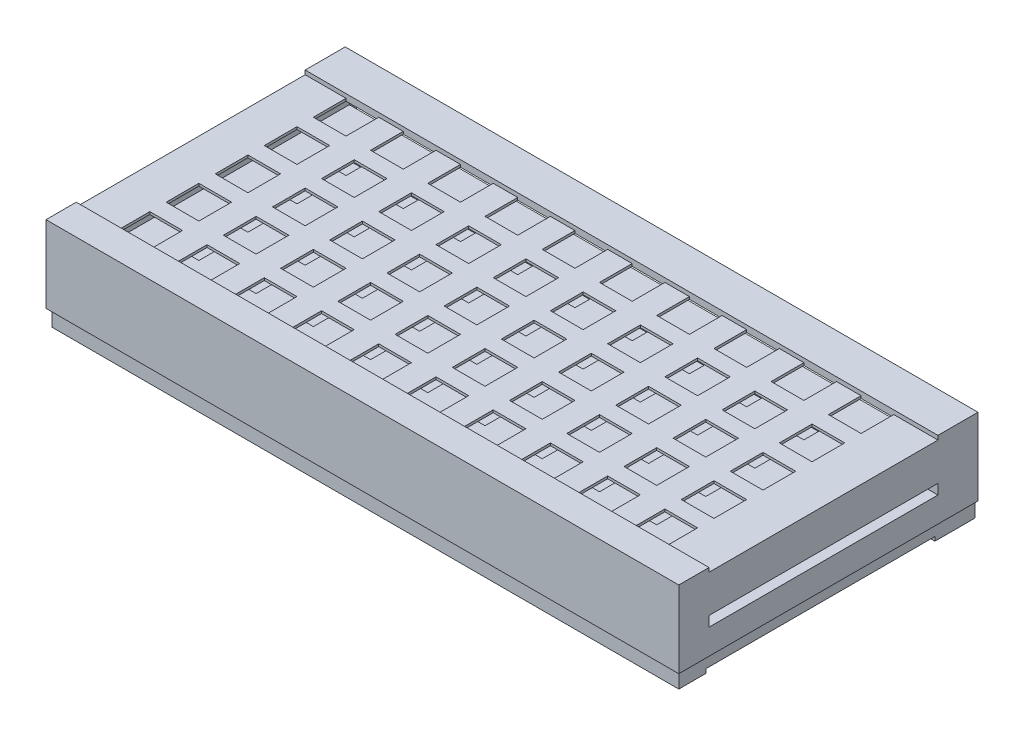
from build123d import *

# Parameters (mm, degrees)
SZKIC1_W                     = 374
SZKIC1_H                     = 53
DODANIE_WYCI_GNI_CIE1_DEPTH  = 177
SZKIC5_W                     = 20
SZKIC5_H                     = 20
WYTNIJ_WYCI_GNI_CIE4_DEPTH   = 104
SZKIC7_W                     = 370
SZKIC7_H                     = 19.4
WYTNIJ_WYCI_GNI_CIE5_DEPTH   = 175
SZKIC9_W                     = 140
SZKIC9_H                     = 6.2
WYTNIJ_WYCI_GNI_CIE6_DEPTH   = 374
SZKIC15_W                    = 374
SZKIC15_H                    = 177
SZKIC15_W_2                  = 20
SZKIC15_H_2                  = 20
DODANIE_WYCI_GNI_CIE6_DEPTH  = 1
SZKIC16_W                    = 374
SZKIC16_H                    = 177
SZKIC16_W_2                  = 20
SZKIC16_H_2                  = 20
DODANIE_WYCI_GNI_CIE7_DEPTH  = 1
SZKIC17_W                    = 177
SZKIC17_H                    = 55
SZKIC17_W_2                  = 140
SZKIC17_H_2                  = 6.2
DODANIE_WYCI_GNI_CIE8_DEPTH  = 1
SZKIC18_W                    = 177
SZKIC18_H                    = 55
SZKIC18_W_2                  = 140
SZKIC18_H_2                  = 6.2
DODANIE_WYCI_GNI_CIE9_DEPTH  = 1
SZKIC19_W                    = 376
SZKIC19_H                    = 55
SZKIC19_W_2                  = 373
SZKIC19_H_2                  = 52
DODANIE_WYCI_GNI_CIE10_DEPTH = 6
SZKIC21_W                    = 376
SZKIC21_H                    = 140
WYTNIJ_WYCI_GNI_CIE7_DEPTH   = 1.5
SZKIC22_W                    = 376
SZKIC22_H                    = 140
WYTNIJ_WYCI_GNI_CIE8_DEPTH   = 1.5
SZKIC23_W                    = 140
SZKIC23_H                    = 6.2
DODANIE_WYCI_GNI_CIE11_DEPTH = 5.5
SZKIC24_W                    = 140
SZKIC24_H                    = 6.2
DODANIE_WYCI_GNI_CIE12_DEPTH = 5.5
SZKIC25_W                    = 387
SZKIC25_H                    = 24.5
SZKIC25_H_2                  = 18.5
DODANIE_WYCI_GNI_CIE13_DEPTH = 1
SZKIC26_W                    = 387
SZKIC26_H                    = 24.5
SZKIC26_H_2                  = 18.5
DODANIE_WYCI_GNI_CIE14_DEPTH = 1
SZKIC31_W                    = 387
SZKIC31_H                    = 10
WYTNIJ_WYCI_GNI_CIE12_DEPTH  = 1.85
WYTNIJ_WYCI_GNI_CIE13_DEPTH  = 1.85
WYTNIJ_WYCI_GNI_CIE14_DEPTH  = 1.85


with BuildPart() as part:
    # Szkic1 → Dodanie-wyciągnięcie1 (new body)
    with BuildSketch(Plane.XY):
        with Locations((-1, 7.6)):
            Rectangle(SZKIC1_W, SZKIC1_H)
    extrude(amount=DODANIE_WYCI_GNI_CIE1_DEPTH)

    # Szkic5 → Wytnij-wyciągnięcie4 (cut)
    with BuildSketch(Plane.XZ.offset(18.9)):
        with Locations((155.5, 58.5)):
            Rectangle(SZKIC5_W, SZKIC5_H)
        with Locations((155.5, 28.5)):
            Rectangle(SZKIC5_W, SZKIC5_H)
        with Locations((155.5, 88.5)):
            Rectangle(SZKIC5_W, SZKIC5_H)
        with Locations((155.5, 118.5)):
            Rectangle(SZKIC5_W, SZKIC5_H)
        with Locations((155.5, 148.5)):
            Rectangle(SZKIC5_W, SZKIC5_H)
        with Locations((120.5, 58.5)):
            Rectangle(SZKIC5_W, SZKIC5_H)
        with Locations((120.5, 28.5)):
            Rectangle(SZKIC5_W, SZKIC5_H)
        with Locations((120.5, 88.5)):
            Rectangle(SZKIC5_W, SZKIC5_H)
        with Locations((120.5, 118.5)):
            Rectangle(SZKIC5_W, SZKIC5_H)
        with Locations((120.5, 148.5)):
            Rectangle(SZKIC5_W, SZKIC5_H)
        with Locations((85.5, 58.5)):
            Rectangle(SZKIC5_W, SZKIC5_H)
        with Locations((85.5, 28.5)):
            Rectangle(SZKIC5_W, SZKIC5_H)
        with Locations((85.5, 88.5)):
            Rectangle(SZKIC5_W, SZKIC5_H)
        with Locations((85.5, 118.5)):
            Rectangle(SZKIC5_W, SZKIC5_H)
        with Locations((85.5, 148.5)):
            Rectangle(SZKIC5_W, SZKIC5_H)
        with Locations((50.5, 58.5)):
            Rectangle(SZKIC5_W, SZKIC5_H)
        with Locations((50.5, 28.5)):
            Rectangle(SZKIC5_W, SZKIC5_H)
        with Locations((50.5, 88.5)):
            Rectangle(SZKIC5_W, SZKIC5_H)
        with Locations((50.5, 118.5)):
            Rectangle(SZKIC5_W, SZKIC5_H)
        with Locations((50.5, 148.5)):
            Rectangle(SZKIC5_W, SZKIC5_H)
        with Locations((15.5, 58.5)):
            Rectangle(SZKIC5_W, SZKIC5_H)
        with Locations((15.5, 28.5)):
            Rectangle(SZKIC5_W, SZKIC5_H)
        with Locations((15.5, 88.5)):
            Rectangle(SZKIC5_W, SZKIC5_H)
        with Locations((15.5, 118.5)):
            Rectangle(SZKIC5_W, SZKIC5_H)
        with Locations((15.5, 148.5)):
            Rectangle(SZKIC5_W, SZKIC5_H)
        with Locations((-19.5, 58.5)):
            Rectangle(SZKIC5_W, SZKIC5_H)
        with Locations((-19.5, 28.5)):
            Rectangle(SZKIC5_W, SZKIC5_H)
        with Locations((-19.5, 88.5)):
            Rectangle(SZKIC5_W, SZKIC5_H)
        with Locations((-19.5, 118.5)):
            Rectangle(SZKIC5_W, SZKIC5_H)
        with Locations((-19.5, 148.5)):
            Rectangle(SZKIC5_W, SZKIC5_H)
        with Locations((-54.5, 58.5)):
            Rectangle(SZKIC5_W, SZKIC5_H)
        with Locations((-54.5, 28.5)):
            Rectangle(SZKIC5_W, SZKIC5_H)
        with Locations((-54.5, 88.5)):
            Rectangle(SZKIC5_W, SZKIC5_H)
        with Locations((-54.5, 118.5)):
            Rectangle(SZKIC5_W, SZKIC5_H)
        with Locations((-54.5, 148.5)):
            Rectangle(SZKIC5_W, SZKIC5_H)
        with Locations((-89.5, 58.5)):
            Rectangle(SZKIC5_W, SZKIC5_H)
        with Locations((-89.5, 28.5)):
            Rectangle(SZKIC5_W, SZKIC5_H)
        with Locations((-89.5, 88.5)):
            Rectangle(SZKIC5_W, SZKIC5_H)
        with Locations((-89.5, 118.5)):
            Rectangle(SZKIC5_W, SZKIC5_H)
        with Locations((-89.5, 148.5)):
            Rectangle(SZKIC5_W, SZKIC5_H)
        with Locations((-124.5, 58.5)):
            Rectangle(SZKIC5_W, SZKIC5_H)
        with Locations((-124.5, 28.5)):
            Rectangle(SZKIC5_W, SZKIC5_H)
        with Locations((-124.5, 88.5)):
            Rectangle(SZKIC5_W, SZKIC5_H)
        with Locations((-124.5, 118.5)):
            Rectangle(SZKIC5_W, SZKIC5_H)
        with Locations((-124.5, 148.5)):
            Rectangle(SZKIC5_W, SZKIC5_H)
        with Locations((-159.5, 58.5)):
            Rectangle(SZKIC5_W, SZKIC5_H)
        with Locations((-159.5, 28.5)):
            Rectangle(SZKIC5_W, SZKIC5_H)
        with Locations((-159.5, 88.5)):
            Rectangle(SZKIC5_W, SZKIC5_H)
        with Locations((-159.5, 118.5)):
            Rectangle(SZKIC5_W, SZKIC5_H)
        with Locations((-159.5, 148.5)):
            Rectangle(SZKIC5_W, SZKIC5_H)
    extrude(amount=-WYTNIJ_WYCI_GNI_CIE4_DEPTH, mode=Mode.SUBTRACT)

    # Szkic7 → Wytnij-wyciągnięcie5 (cut)
    with BuildSketch(Plane(origin=(0, 0, 0), x_dir=(-1, 0, 0), z_dir=(0, 0, -1))):
        with Locations((1, 22.4)):
            Rectangle(SZKIC7_W, SZKIC7_H)
        with Locations((1, -7.2)):
            Rectangle(SZKIC7_W, SZKIC7_H)
    extrude(amount=-WYTNIJ_WYCI_GNI_CIE5_DEPTH, mode=Mode.SUBTRACT)

    # Szkic9 → Wytnij-wyciągnięcie6 (cut)
    with BuildSketch(Plane(origin=(186, 0, 0), x_dir=(0, 0, -1), z_dir=(1, 0, 0))):
        with Locations((-88.5, 7.6)):
            Rectangle(SZKIC9_W, SZKIC9_H)
    extrude(amount=-WYTNIJ_WYCI_GNI_CIE6_DEPTH, mode=Mode.SUBTRACT)

    # Szkic15 → Dodanie-wyciągnięcie6 (add)
    with BuildSketch(Plane(origin=(0, 34.1, 0), x_dir=(1, 0, 0), z_dir=(0, 1, 0))):
        with Locations((-1, -88.5)):
            Rectangle(SZKIC15_W, SZKIC15_H)
        with Locations((-159.5, -28.5)):
            Rectangle(SZKIC15_W_2, SZKIC15_H_2, mode=Mode.SUBTRACT)
        with Locations((-124.5, -28.5)):
            Rectangle(SZKIC15_W_2, SZKIC15_H_2, mode=Mode.SUBTRACT)
        with Locations((-89.5, -28.5)):
            Rectangle(SZKIC15_W_2, SZKIC15_H_2, mode=Mode.SUBTRACT)
        with Locations((-54.5, -28.5)):
            Rectangle(SZKIC15_W_2, SZKIC15_H_2, mode=Mode.SUBTRACT)
        with Locations((-19.5, -28.5)):
            Rectangle(SZKIC15_W_2, SZKIC15_H_2, mode=Mode.SUBTRACT)
        with Locations((15.5, -28.5)):
            Rectangle(SZKIC15_W_2, SZKIC15_H_2, mode=Mode.SUBTRACT)
        with Locations((50.5, -28.5)):
            Rectangle(SZKIC15_W_2, SZKIC15_H_2, mode=Mode.SUBTRACT)
        with Locations((85.5, -28.5)):
            Rectangle(SZKIC15_W_2, SZKIC15_H_2, mode=Mode.SUBTRACT)
        with Locations((120.5, -28.5)):
            Rectangle(SZKIC15_W_2, SZKIC15_H_2, mode=Mode.SUBTRACT)
        with Locations((155.5, -28.5)):
            Rectangle(SZKIC15_W_2, SZKIC15_H_2, mode=Mode.SUBTRACT)
        with Locations((155.5, -58.5)):
            Rectangle(SZKIC15_W_2, SZKIC15_H_2, mode=Mode.SUBTRACT)
        with Locations((155.5, -88.5)):
            Rectangle(SZKIC15_W_2, SZKIC15_H_2, mode=Mode.SUBTRACT)
        with Locations((155.5, -118.5)):
            Rectangle(SZKIC15_W_2, SZKIC15_H_2, mode=Mode.SUBTRACT)
        with Locations((155.5, -148.5)):
            Rectangle(SZKIC15_W_2, SZKIC15_H_2, mode=Mode.SUBTRACT)
        with Locations((120.5, -58.5)):
            Rectangle(SZKIC15_W_2, SZKIC15_H_2, mode=Mode.SUBTRACT)
        with Locations((120.5, -88.5)):
            Rectangle(SZKIC15_W_2, SZKIC15_H_2, mode=Mode.SUBTRACT)
        with Locations((120.5, -118.5)):
            Rectangle(SZKIC15_W_2, SZKIC15_H_2, mode=Mode.SUBTRACT)
        with Locations((120.5, -148.5)):
            Rectangle(SZKIC15_W_2, SZKIC15_H_2, mode=Mode.SUBTRACT)
        with Locations((85.5, -58.5)):
            Rectangle(SZKIC15_W_2, SZKIC15_H_2, mode=Mode.SUBTRACT)
        with Locations((85.5, -88.5)):
            Rectangle(SZKIC15_W_2, SZKIC15_H_2, mode=Mode.SUBTRACT)
        with Locations((85.5, -118.5)):
            Rectangle(SZKIC15_W_2, SZKIC15_H_2, mode=Mode.SUBTRACT)
        with Locations((85.5, -148.5)):
            Rectangle(SZKIC15_W_2, SZKIC15_H_2, mode=Mode.SUBTRACT)
        with Locations((50.5, -58.5)):
            Rectangle(SZKIC15_W_2, SZKIC15_H_2, mode=Mode.SUBTRACT)
        with Locations((50.5, -88.5)):
            Rectangle(SZKIC15_W_2, SZKIC15_H_2, mode=Mode.SUBTRACT)
        with Locations((50.5, -118.5)):
            Rectangle(SZKIC15_W_2, SZKIC15_H_2, mode=Mode.SUBTRACT)
        with Locations((15.5, -58.5)):
            Rectangle(SZKIC15_W_2, SZKIC15_H_2, mode=Mode.SUBTRACT)
        with Locations((15.5, -88.5)):
            Rectangle(SZKIC15_W_2, SZKIC15_H_2, mode=Mode.SUBTRACT)
        with Locations((15.5, -118.5)):
            Rectangle(SZKIC15_W_2, SZKIC15_H_2, mode=Mode.SUBTRACT)
        with Locations((15.5, -148.5)):
            Rectangle(SZKIC15_W_2, SZKIC15_H_2, mode=Mode.SUBTRACT)
        with Locations((50.5, -148.5)):
            Rectangle(SZKIC15_W_2, SZKIC15_H_2, mode=Mode.SUBTRACT)
        with Locations((-19.5, -58.5)):
            Rectangle(SZKIC15_W_2, SZKIC15_H_2, mode=Mode.SUBTRACT)
        with Locations((-19.5, -88.5)):
            Rectangle(SZKIC15_W_2, SZKIC15_H_2, mode=Mode.SUBTRACT)
        with Locations((-19.5, -118.5)):
            Rectangle(SZKIC15_W_2, SZKIC15_H_2, mode=Mode.SUBTRACT)
        with Locations((-19.5, -148.5)):
            Rectangle(SZKIC15_W_2, SZKIC15_H_2, mode=Mode.SUBTRACT)
        with Locations((-54.5, -58.5)):
            Rectangle(SZKIC15_W_2, SZKIC15_H_2, mode=Mode.SUBTRACT)
        with Locations((-54.5, -88.5)):
            Rectangle(SZKIC15_W_2, SZKIC15_H_2, mode=Mode.SUBTRACT)
        with Locations((-54.5, -118.5)):
            Rectangle(SZKIC15_W_2, SZKIC15_H_2, mode=Mode.SUBTRACT)
        with Locations((-54.5, -148.5)):
            Rectangle(SZKIC15_W_2, SZKIC15_H_2, mode=Mode.SUBTRACT)
        with Locations((-89.5, -58.5)):
            Rectangle(SZKIC15_W_2, SZKIC15_H_2, mode=Mode.SUBTRACT)
        with Locations((-89.5, -88.5)):
            Rectangle(SZKIC15_W_2, SZKIC15_H_2, mode=Mode.SUBTRACT)
        with Locations((-89.5, -118.5)):
            Rectangle(SZKIC15_W_2, SZKIC15_H_2, mode=Mode.SUBTRACT)
        with Locations((-89.5, -148.5)):
            Rectangle(SZKIC15_W_2, SZKIC15_H_2, mode=Mode.SUBTRACT)
        with Locations((-124.5, -58.5)):
            Rectangle(SZKIC15_W_2, SZKIC15_H_2, mode=Mode.SUBTRACT)
        with Locations((-124.5, -88.5)):
            Rectangle(SZKIC15_W_2, SZKIC15_H_2, mode=Mode.SUBTRACT)
        with Locations((-124.5, -118.5)):
            Rectangle(SZKIC15_W_2, SZKIC15_H_2, mode=Mode.SUBTRACT)
        with Locations((-124.5, -148.5)):
            Rectangle(SZKIC15_W_2, SZKIC15_H_2, mode=Mode.SUBTRACT)
        with Locations((-159.5, -58.5)):
            Rectangle(SZKIC15_W_2, SZKIC15_H_2, mode=Mode.SUBTRACT)
        with Locations((-159.5, -88.5)):
            Rectangle(SZKIC15_W_2, SZKIC15_H_2, mode=Mode.SUBTRACT)
        with Locations((-159.5, -118.5)):
            Rectangle(SZKIC15_W_2, SZKIC15_H_2, mode=Mode.SUBTRACT)
        with Locations((-159.5, -148.5)):
            Rectangle(SZKIC15_W_2, SZKIC15_H_2, mode=Mode.SUBTRACT)
    extrude(amount=DODANIE_WYCI_GNI_CIE6_DEPTH)

    # Szkic16 → Dodanie-wyciągnięcie7 (add)
    with BuildSketch(Plane.XZ.offset(18.9)):
        with Locations((-1, 88.5)):
            Rectangle(SZKIC16_W, SZKIC16_H)
        with Locations((155.5, 28.5)):
            Rectangle(SZKIC16_W_2, SZKIC16_H_2, mode=Mode.SUBTRACT)
        with Locations((120.5, 28.5)):
            Rectangle(SZKIC16_W_2, SZKIC16_H_2, mode=Mode.SUBTRACT)
        with Locations((85.5, 28.5)):
            Rectangle(SZKIC16_W_2, SZKIC16_H_2, mode=Mode.SUBTRACT)
        with Locations((50.5, 28.5)):
            Rectangle(SZKIC16_W_2, SZKIC16_H_2, mode=Mode.SUBTRACT)
        with Locations((15.5, 28.5)):
            Rectangle(SZKIC16_W_2, SZKIC16_H_2, mode=Mode.SUBTRACT)
        with Locations((-19.5, 28.5)):
            Rectangle(SZKIC16_W_2, SZKIC16_H_2, mode=Mode.SUBTRACT)
        with Locations((-54.5, 28.5)):
            Rectangle(SZKIC16_W_2, SZKIC16_H_2, mode=Mode.SUBTRACT)
        with Locations((-89.5, 28.5)):
            Rectangle(SZKIC16_W_2, SZKIC16_H_2, mode=Mode.SUBTRACT)
        with Locations((-124.5, 28.5)):
            Rectangle(SZKIC16_W_2, SZKIC16_H_2, mode=Mode.SUBTRACT)
        with Locations((-159.5, 28.5)):
            Rectangle(SZKIC16_W_2, SZKIC16_H_2, mode=Mode.SUBTRACT)
        with Locations((155.5, 58.5)):
            Rectangle(SZKIC16_W_2, SZKIC16_H_2, mode=Mode.SUBTRACT)
        with Locations((120.5, 58.5)):
            Rectangle(SZKIC16_W_2, SZKIC16_H_2, mode=Mode.SUBTRACT)
        with Locations((85.5, 58.5)):
            Rectangle(SZKIC16_W_2, SZKIC16_H_2, mode=Mode.SUBTRACT)
        with Locations((50.5, 58.5)):
            Rectangle(SZKIC16_W_2, SZKIC16_H_2, mode=Mode.SUBTRACT)
        with Locations((15.5, 58.5)):
            Rectangle(SZKIC16_W_2, SZKIC16_H_2, mode=Mode.SUBTRACT)
        with Locations((-19.5, 58.5)):
            Rectangle(SZKIC16_W_2, SZKIC16_H_2, mode=Mode.SUBTRACT)
        with Locations((-54.5, 58.5)):
            Rectangle(SZKIC16_W_2, SZKIC16_H_2, mode=Mode.SUBTRACT)
        with Locations((-89.5, 58.5)):
            Rectangle(SZKIC16_W_2, SZKIC16_H_2, mode=Mode.SUBTRACT)
        with Locations((-124.5, 58.5)):
            Rectangle(SZKIC16_W_2, SZKIC16_H_2, mode=Mode.SUBTRACT)
        with Locations((-159.5, 58.5)):
            Rectangle(SZKIC16_W_2, SZKIC16_H_2, mode=Mode.SUBTRACT)
        with Locations((-159.5, 88.5)):
            Rectangle(SZKIC16_W_2, SZKIC16_H_2, mode=Mode.SUBTRACT)
        with Locations((-159.5, 118.5)):
            Rectangle(SZKIC16_W_2, SZKIC16_H_2, mode=Mode.SUBTRACT)
        with Locations((-159.5, 148.5)):
            Rectangle(SZKIC16_W_2, SZKIC16_H_2, mode=Mode.SUBTRACT)
        with Locations((-124.5, 88.5)):
            Rectangle(SZKIC16_W_2, SZKIC16_H_2, mode=Mode.SUBTRACT)
        with Locations((-124.5, 118.5)):
            Rectangle(SZKIC16_W_2, SZKIC16_H_2, mode=Mode.SUBTRACT)
        with Locations((-124.5, 148.5)):
            Rectangle(SZKIC16_W_2, SZKIC16_H_2, mode=Mode.SUBTRACT)
        with Locations((-89.5, 88.5)):
            Rectangle(SZKIC16_W_2, SZKIC16_H_2, mode=Mode.SUBTRACT)
        with Locations((-89.5, 118.5)):
            Rectangle(SZKIC16_W_2, SZKIC16_H_2, mode=Mode.SUBTRACT)
        with Locations((-89.5, 148.5)):
            Rectangle(SZKIC16_W_2, SZKIC16_H_2, mode=Mode.SUBTRACT)
        with Locations((-54.5, 88.5)):
            Rectangle(SZKIC16_W_2, SZKIC16_H_2, mode=Mode.SUBTRACT)
        with Locations((-54.5, 118.5)):
            Rectangle(SZKIC16_W_2, SZKIC16_H_2, mode=Mode.SUBTRACT)
        with Locations((-54.5, 148.5)):
            Rectangle(SZKIC16_W_2, SZKIC16_H_2, mode=Mode.SUBTRACT)
        with Locations((-19.5, 88.5)):
            Rectangle(SZKIC16_W_2, SZKIC16_H_2, mode=Mode.SUBTRACT)
        with Locations((-19.5, 118.5)):
            Rectangle(SZKIC16_W_2, SZKIC16_H_2, mode=Mode.SUBTRACT)
        with Locations((-19.5, 148.5)):
            Rectangle(SZKIC16_W_2, SZKIC16_H_2, mode=Mode.SUBTRACT)
        with Locations((15.5, 88.5)):
            Rectangle(SZKIC16_W_2, SZKIC16_H_2, mode=Mode.SUBTRACT)
        with Locations((15.5, 118.5)):
            Rectangle(SZKIC16_W_2, SZKIC16_H_2, mode=Mode.SUBTRACT)
        with Locations((15.5, 148.5)):
            Rectangle(SZKIC16_W_2, SZKIC16_H_2, mode=Mode.SUBTRACT)
        with Locations((50.5, 88.5)):
            Rectangle(SZKIC16_W_2, SZKIC16_H_2, mode=Mode.SUBTRACT)
        with Locations((50.5, 118.5)):
            Rectangle(SZKIC16_W_2, SZKIC16_H_2, mode=Mode.SUBTRACT)
        with Locations((50.5, 148.5)):
            Rectangle(SZKIC16_W_2, SZKIC16_H_2, mode=Mode.SUBTRACT)
        with Locations((85.5, 88.5)):
            Rectangle(SZKIC16_W_2, SZKIC16_H_2, mode=Mode.SUBTRACT)
        with Locations((85.5, 118.5)):
            Rectangle(SZKIC16_W_2, SZKIC16_H_2, mode=Mode.SUBTRACT)
        with Locations((85.5, 148.5)):
            Rectangle(SZKIC16_W_2, SZKIC16_H_2, mode=Mode.SUBTRACT)
        with Locations((120.5, 88.5)):
            Rectangle(SZKIC16_W_2, SZKIC16_H_2, mode=Mode.SUBTRACT)
        with Locations((155.5, 88.5)):
            Rectangle(SZKIC16_W_2, SZKIC16_H_2, mode=Mode.SUBTRACT)
        with Locations((155.5, 118.5)):
            Rectangle(SZKIC16_W_2, SZKIC16_H_2, mode=Mode.SUBTRACT)
        with Locations((120.5, 118.5)):
            Rectangle(SZKIC16_W_2, SZKIC16_H_2, mode=Mode.SUBTRACT)
        with Locations((155.5, 148.5)):
            Rectangle(SZKIC16_W_2, SZKIC16_H_2, mode=Mode.SUBTRACT)
        with Locations((120.5, 148.5)):
            Rectangle(SZKIC16_W_2, SZKIC16_H_2, mode=Mode.SUBTRACT)
    extrude(amount=DODANIE_WYCI_GNI_CIE7_DEPTH)

    # Szkic17 → Dodanie-wyciągnięcie8 (add)
    with BuildSketch(Plane(origin=(186, 0, 0), x_dir=(0, 0, -1), z_dir=(1, 0, 0))):
        with Locations((-88.5, 7.6)):
            Rectangle(SZKIC17_W, SZKIC17_H)
        with Locations((-88.5, 7.6)):
            Rectangle(SZKIC17_W_2, SZKIC17_H_2, mode=Mode.SUBTRACT)
    extrude(amount=DODANIE_WYCI_GNI_CIE8_DEPTH)

    # Szkic18 → Dodanie-wyciągnięcie9 (add)
    with BuildSketch(Plane.ZY.offset(188)):
        with Locations((88.5, 7.6)):
            Rectangle(SZKIC18_W, SZKIC18_H)
        with Locations((88.5, 7.6)):
            Rectangle(SZKIC18_W_2, SZKIC18_H_2, mode=Mode.SUBTRACT)
    extrude(amount=DODANIE_WYCI_GNI_CIE9_DEPTH)

    # Szkic19 → Dodanie-wyciągnięcie10 (add)
    with BuildSketch(Plane(origin=(0, 0, 0), x_dir=(-1, 0, 0), z_dir=(0, 0, -1))):
        with Locations((1, 7.6)):
            Rectangle(SZKIC19_W, SZKIC19_H)
        with Locations((1, 7.6)):
            Rectangle(SZKIC19_W_2, SZKIC19_H_2, mode=Mode.SUBTRACT)
    extrude(amount=DODANIE_WYCI_GNI_CIE10_DEPTH)

    # Szkic21 → Wytnij-wyciągnięcie7 (cut)
    with BuildSketch(Plane(origin=(0, 35.1, 0), x_dir=(1, 0, 0), z_dir=(0, 1, 0))):
        with Locations((-1, -88.5)):
            Rectangle(SZKIC21_W, SZKIC21_H)
    extrude(amount=-WYTNIJ_WYCI_GNI_CIE7_DEPTH, mode=Mode.SUBTRACT)

    # Szkic22 → Wytnij-wyciągnięcie8 (cut)
    with BuildSketch(Plane.XZ.offset(19.9)):
        with Locations((-1, 88.5)):
            Rectangle(SZKIC22_W, SZKIC22_H)
    extrude(amount=-WYTNIJ_WYCI_GNI_CIE8_DEPTH, mode=Mode.SUBTRACT)

    # Szkic23 → Dodanie-wyciągnięcie11 (add)
    with BuildSketch(Plane(origin=(187, 0, 0), x_dir=(0, 0, -1), z_dir=(1, 0, 0))):
        Polygon((6, 35.1), (6, -19.9), (-18.5, -19.9), (-18.5, -18.4), (-158.5, -18.4), (-158.5, -19.9), (-177, -19.9), (-177, 35.1), (-158.5, 35.1), (-158.5, 33.6), (-18.5, 33.6), (-18.5, 35.1), align=None)
        with Locations((-88.5, 7.6)):
            Rectangle(SZKIC23_W, SZKIC23_H, mode=Mode.SUBTRACT)
    extrude(amount=DODANIE_WYCI_GNI_CIE11_DEPTH)

    # Szkic24 → Dodanie-wyciągnięcie12 (add)
    with BuildSketch(Plane.ZY.offset(189)):
        Polygon((-6, -19.9), (-6, 35.1), (18.5, 35.1), (18.5, 33.6), (158.5, 33.6), (158.5, 35.1), (177, 35.1), (177, -19.9), (158.5, -19.9), (158.5, -18.4), (18.5, -18.4), (18.5, -19.9), align=None)
        with Locations((88.5, 7.6)):
            Rectangle(SZKIC24_W, SZKIC24_H, mode=Mode.SUBTRACT)
    extrude(amount=DODANIE_WYCI_GNI_CIE12_DEPTH)

    # Szkic25 → Dodanie-wyciągnięcie13 (add)
    with BuildSketch(Plane.XZ.offset(19.9)):
        with Locations((-1, 6.25)):
            Rectangle(SZKIC25_W, SZKIC25_H)
        with Locations((-1, 167.75)):
            Rectangle(SZKIC25_W, SZKIC25_H_2)
    extrude(amount=DODANIE_WYCI_GNI_CIE13_DEPTH)

    # Szkic26 → Dodanie-wyciągnięcie14 (add)
    with BuildSketch(Plane(origin=(0, 35.1, 0), x_dir=(1, 0, 0), z_dir=(0, 1, 0))):
        with Locations((-1, -6.25)):
            Rectangle(SZKIC26_W, SZKIC26_H)
        with Locations((-1, -167.75)):
            Rectangle(SZKIC26_W, SZKIC26_H_2)
    extrude(amount=DODANIE_WYCI_GNI_CIE14_DEPTH)

    # Szkic31 → Wytnij-wyciągnięcie12 (cut)
    with BuildSketch(Plane.XY.offset(177)):
        with Locations((-1, -15.9)):
            Rectangle(SZKIC31_W, SZKIC31_H)
    extrude(amount=-WYTNIJ_WYCI_GNI_CIE12_DEPTH, mode=Mode.SUBTRACT)

    # Szkic32 → Wytnij-wyciągnięcie13 (cut)
    with BuildSketch(Plane(origin=(192.5, 0, 0), x_dir=(0, 0, -1), z_dir=(1, 0, 0))):
        Polygon((-175.15, -10.9), (6, -10.9), (6, -20.9), (-18.5, -20.9), (-18.5, -18.4), (-158.5, -18.4), (-158.5, -20.9), (-175.15, -20.9), align=None)
    extrude(amount=-WYTNIJ_WYCI_GNI_CIE13_DEPTH, mode=Mode.SUBTRACT)

    # Szkic33 → Wytnij-wyciągnięcie14 (cut)
    with BuildSketch(Plane.ZY.offset(194.5)):
        Polygon((175.15, -10.9), (-6, -10.9), (-6, -20.9), (18.5, -20.9), (18.5, -18.4), (158.5, -18.4), (158.5, -20.9), (175.15, -20.9), align=None)
    extrude(amount=-WYTNIJ_WYCI_GNI_CIE14_DEPTH, mode=Mode.SUBTRACT)


solid = part.part
